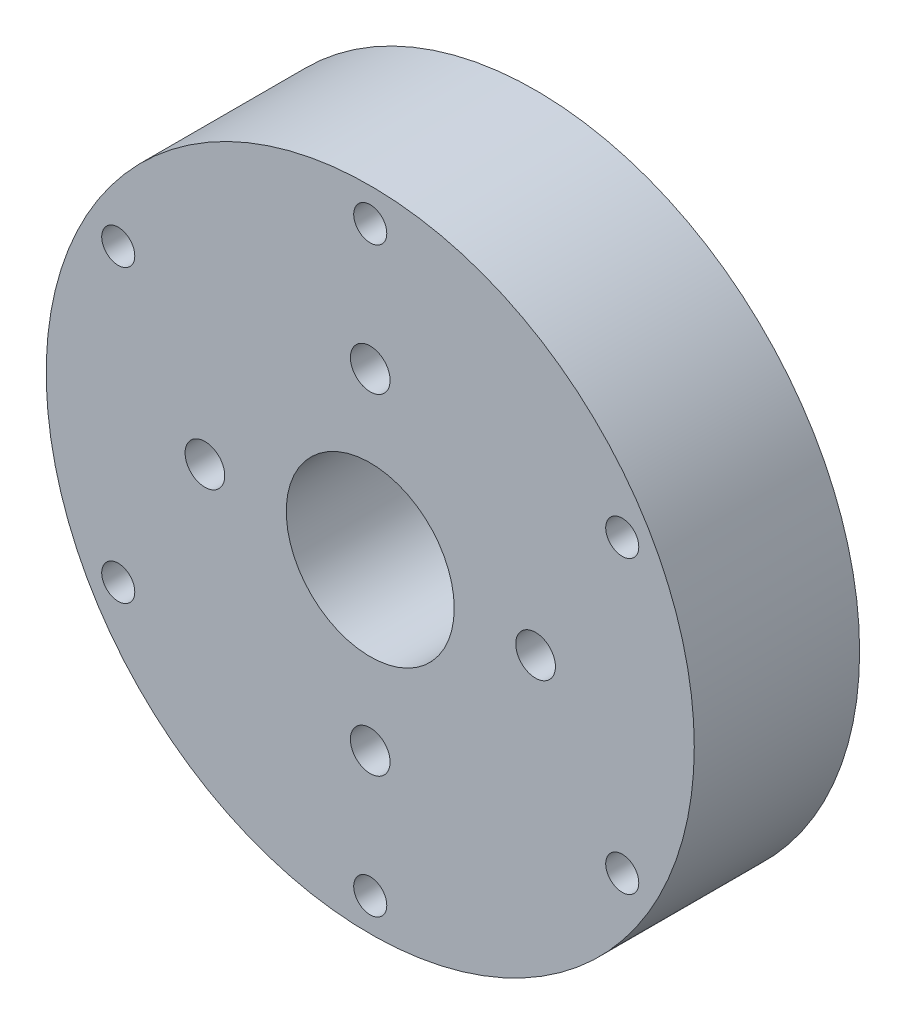
from build123d import *

# Parameters (mm, degrees)
SKETCH_1_R          = 24.5
EXTRUDE_1_DEPTH     = 12.5
SKETCH_2_R          = 1.25
CUT_EXTRUDE_1_DEPTH = 3
SKETCH_3_R          = 1.5
CUT_EXTRUDE_2_DEPTH = 3.5
SKETCH_5_R          = 6.35
CUT_EXTRUDE_3_DEPTH = 10


with BuildPart() as part:
    # 草图1 → 凸台-拉伸1 (new body)
    with BuildSketch(Plane.XY):
        Circle(SKETCH_1_R)
    extrude(amount=EXTRUDE_1_DEPTH)

    # 草图2 → 切除-拉伸1 (cut)
    with BuildSketch(Plane.XY.offset(12.5)):
        with Locations((0, 22)):
            Circle(SKETCH_2_R)
        with Locations((0, -22)):
            Circle(SKETCH_2_R)
        with Locations((19.052558883, 11)):
            Circle(SKETCH_2_R)
        with Locations((-19.052558883, 11)):
            Circle(SKETCH_2_R)
        with Locations((19.052558883, -11)):
            Circle(SKETCH_2_R)
        with Locations((-19.052558883, -11)):
            Circle(SKETCH_2_R)
    extrude(amount=-CUT_EXTRUDE_1_DEPTH, mode=Mode.SUBTRACT)

    # 草图3 → 切除-拉伸2 (cut)
    with BuildSketch(Plane.XY.offset(12.5)):
        with Locations((0, 12.5)):
            Circle(SKETCH_3_R)
        with Locations((0, -12.5)):
            Circle(SKETCH_3_R)
        with Locations((12.5, 0)):
            Circle(SKETCH_3_R)
        with Locations((-12.5, 0)):
            Circle(SKETCH_3_R)
    extrude(amount=-CUT_EXTRUDE_2_DEPTH, mode=Mode.SUBTRACT)

    # 草图5 → 切除-拉伸3 (cut)
    with BuildSketch(Plane.XY.offset(12.5)):
        Circle(SKETCH_5_R)
    extrude(amount=-CUT_EXTRUDE_3_DEPTH, mode=Mode.SUBTRACT)


solid = part.part
